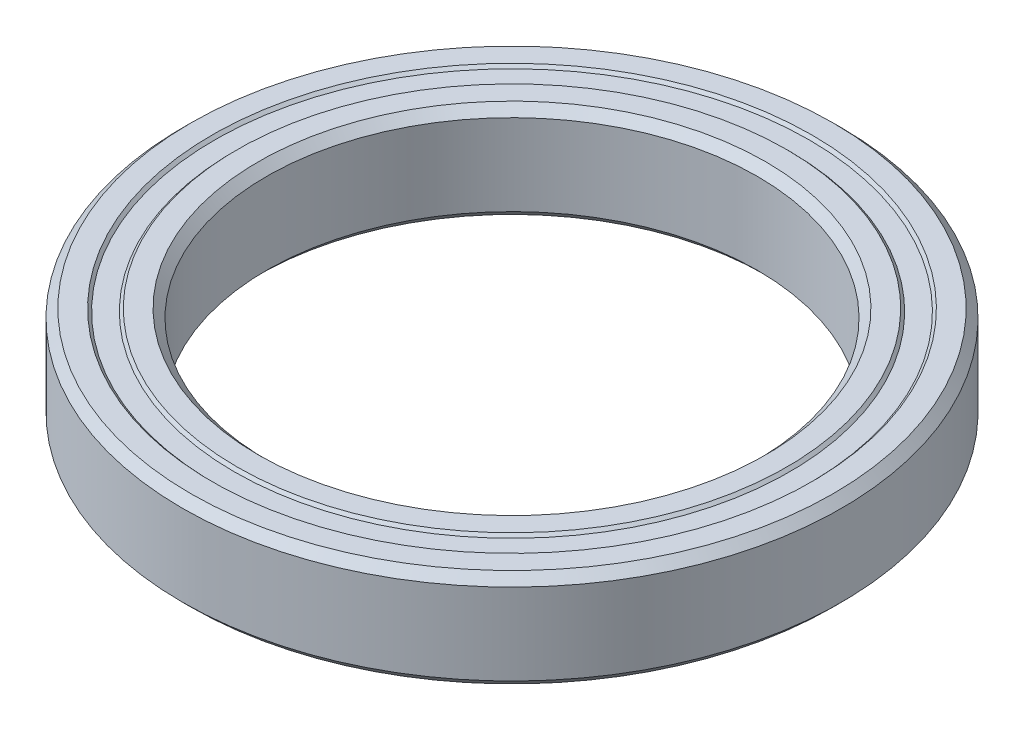
from build123d import *


with BuildPart() as part:
    # Sketch1 → Revolve1 (revolve)
    with BuildSketch(Plane.XY):
        Polygon((17.5, 2.9), (17.5, -2.9), (18.1, -3.5), (19.6, -3.5), (19.8, -3.3), (21.2, -3.3), (21.4, -3.5), (22.9, -3.5), (23.5, -2.9), (23.5, 2.9), (22.9, 3.5), (21.4, 3.5), (21.2, 3.3), (19.8, 3.3), (19.6, 3.5), (18.1, 3.5), align=None)
    revolve(axis=Axis((0, -1.349421972, 0), (0, 1, 0)))


solid = part.part
